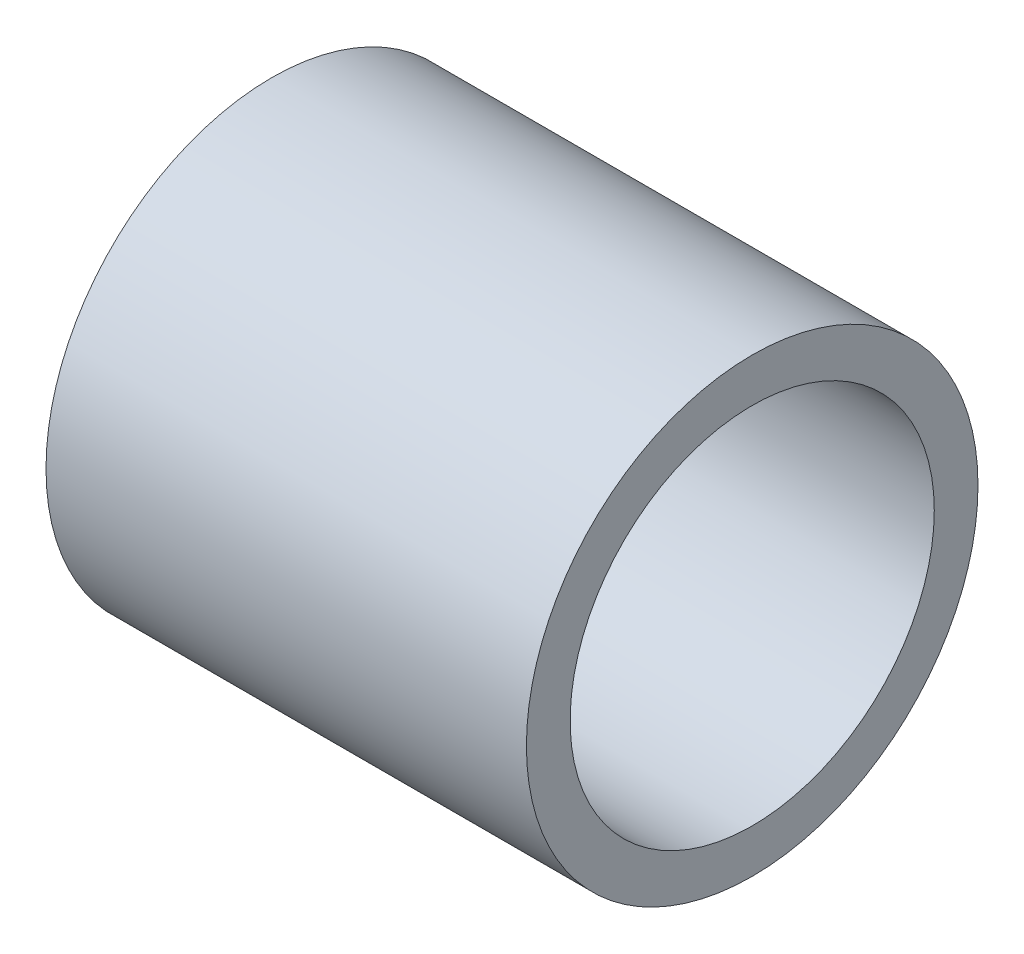
from build123d import *

# Parameters (mm, degrees)
SKETCH3_R                = 5.969
SKETCH3_R_2              = 4.8133
BOSS_EXTRUDE1_DEPTH      = 6.35
BOSS_EXTRUDE1_DEPTH_BACK = 6.35


with BuildPart() as part:
    # Sketch3 → Boss-Extrude1 (new body, two sides)
    with BuildSketch(Plane(origin=(0, 0, 0), x_dir=(0, 0, -1), z_dir=(1, 0, 0))) as boss_extrude1_sk:
        Circle(SKETCH3_R)
        Circle(SKETCH3_R_2, mode=Mode.SUBTRACT)
    extrude(amount=BOSS_EXTRUDE1_DEPTH)
    extrude(boss_extrude1_sk.sketch, amount=-BOSS_EXTRUDE1_DEPTH_BACK)


solid = part.part
